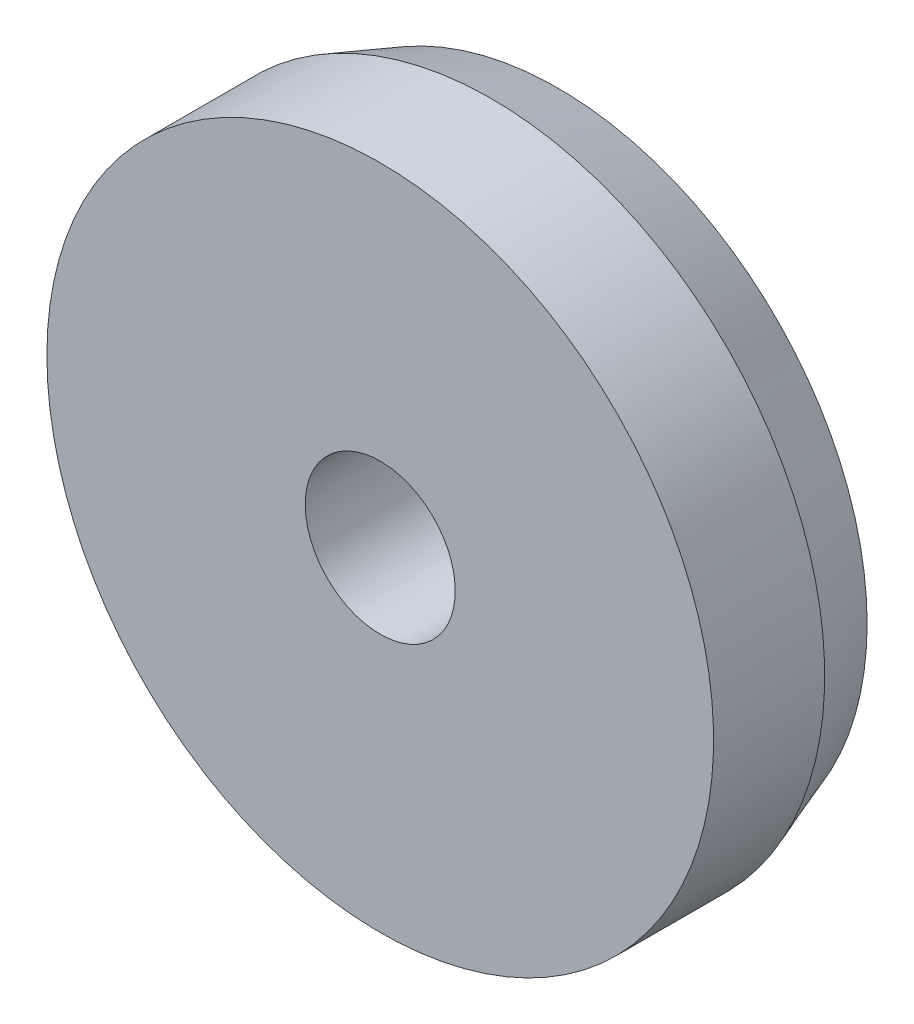
from build123d import *


with BuildPart() as part:
    # Sketch1 → Revolve1 (revolve)
    with BuildSketch(Plane.XZ.offset(6.0740848)):
        with BuildLine():
            Line((-2.062261998, -1.87), (-2.062261998, -1.67))
            Line((-2.062261998, -1.67), (-2.527261998, -1.67))
            Line((-2.527261998, -1.67), (-2.527261998, -1.87))
            ThreePointArc((-2.527261998, -1.87), (-2.36367156, -1.914012599), (-2.212261998, -1.99))
            Line((-2.212261998, -1.99), (-2.105938426, -1.99))
            Line((-2.105938426, -1.99), (-2.062261998, -1.87))
        make_face()
    revolve(axis=Axis((-2.662261998, -6.0740848, -1.67), (0, 0, -1)))


solid = part.part
